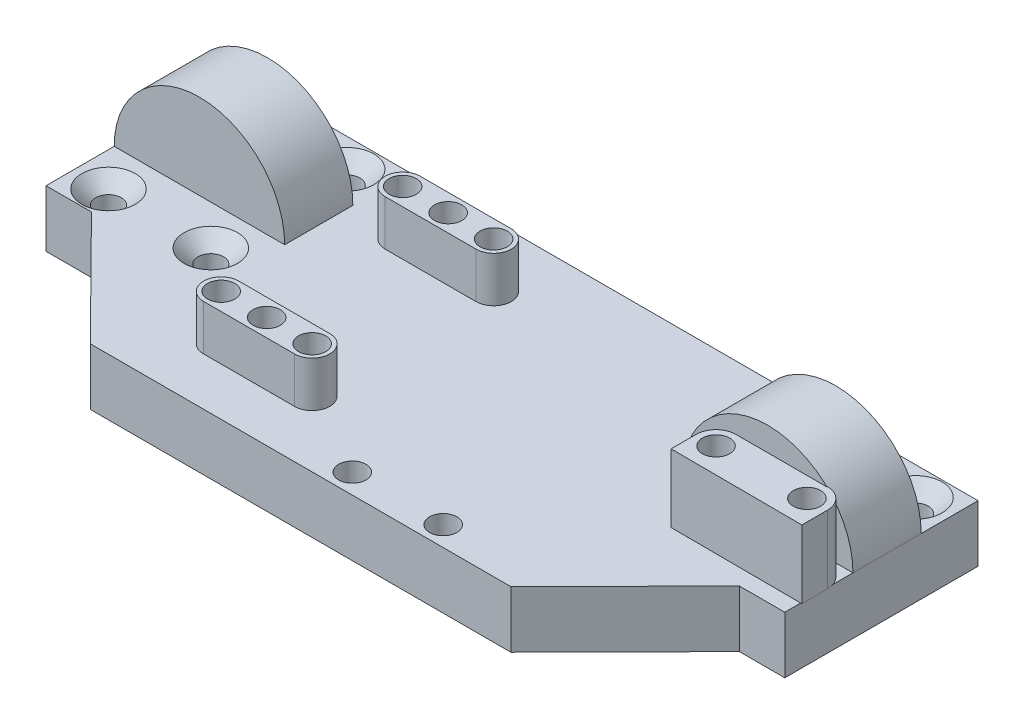
from build123d import *

# Parameters (mm, degrees)
BOSS_EXTRUDE1_DEPTH                             = 10
BOSS_EXTRUDE2_DEPTH                             = 10
SKETCH4_R                                       = 2.4
CUT_EXTRUDE1_DEPTH                              = 8
SKETCH5_R                                       = 2.4
BOSS_EXTRUDE3_DEPTH                             = 12
CSK_FOR_M4_FLAT_HEAD_MACHINE_SCREW1_D           = 4.5
CSK_FOR_M4_FLAT_HEAD_MACHINE_SCREW1_DEPTH       = 10
CSK_FOR_M4_FLAT_HEAD_MACHINE_SCREW1_CSINK_D     = 9.4
CSK_FOR_M4_FLAT_HEAD_MACHINE_SCREW1_CSINK_ANGLE = 90
SKETCH10_R                                      = 2.4
BOSS_EXTRUDE4_DEPTH                             = 8
SKETCH11_R                                      = 4
BOSS_EXTRUDE5_DEPTH                             = 12
SKETCH12_R                                      = 4
BOSS_EXTRUDE6_DEPTH                             = 4


with BuildPart() as part:
    # Sketch2 → Boss-Extrude1 (new body)
    with BuildSketch(Plane(origin=(0, 0, 0), x_dir=(1, 0, 0), z_dir=(0, 1, 0))):
        Polygon((-64.864315762, -10.473994627), (-34.864315762, -10.473994627), (35.135684238, -10.473994627), (65.135684238, -10.473994627), (65.135684238, 23.526005373), (35.135684238, 23.526005373), (-34.864315762, 23.526005373), (-64.864315762, 23.526005373), align=None)
    extrude(amount=BOSS_EXTRUDE1_DEPTH)

    # Sketch3 → Boss-Extrude2 (add)
    with BuildSketch(Plane.XZ):
        Polygon((-34.864315762, 10.473994627), (-17.766011303, 10.473994627), (-17.766011303, 10.772744439), (-17.766011303, 12.772744439), (-17.766011303, 30.672744439), (-36.864315762, 30.672744439), (-56.864315762, 10.473994627), align=None)
        Polygon((-17.766011303, 10.772744439), (-17.766011303, 10.473994627), (35.135684238, 10.473994627), (57.135684238, 10.473994627), (37.135684238, 30.672744439), (-17.766011303, 30.672744439), (-17.766011303, 12.772744439), align=None)
    extrude(amount=-BOSS_EXTRUDE2_DEPTH)

    # Sketch4 → Cut-Extrude1 (cut)
    with BuildSketch(Plane(origin=(0, 10, 0), x_dir=(1, 0, 0), z_dir=(0, 1, 0))):
        with Locations((5.733988697, -27.172744439)):
            Circle(SKETCH4_R)
        with Locations((21.733988697, -27.172744439)):
            Circle(SKETCH4_R)
    extrude(amount=-CUT_EXTRUDE1_DEPTH, mode=Mode.SUBTRACT)

    # Sketch5 → Boss-Extrude3 (add)
    with BuildSketch(Plane(origin=(0, 10, 0), x_dir=(1, 0, 0), z_dir=(0, 1, 0))):
        with BuildLine():
            Line((42.233988697, -7.572744439), (65.333988697, -7.672744439))
            Line((65.333988697, -7.672744439), (65.333988697, -3.172744439))
            ThreePointArc((65.333988697, -3.172744439), (64.279573109, -0.627160027), (61.733988697, 0.427255561))
            Line((61.733988697, 0.427255561), (61.733988697, 0.327255561))
            Line((61.733988697, 0.327255561), (45.733988697, 0.327255561))
            ThreePointArc((45.733988697, 0.327255561), (43.259114963, -0.697870705), (42.233988697, -3.172744439))
            Line((42.233988697, -3.172744439), (42.233988697, -7.572744439))
        make_face()
        with Locations((61.733988697, -3.172744439)):
            Circle(SKETCH5_R, mode=Mode.SUBTRACT)
        with Locations((45.733988697, -3.172744439)):
            Circle(SKETCH5_R, mode=Mode.SUBTRACT)
    extrude(amount=BOSS_EXTRUDE3_DEPTH)

    # CSK for M4 Flat Head Machine Screw1
    with Locations(Plane(origin=(0, 10, 0), x_dir=(1, 0, 0), z_dir=(0, 1, 0))):
        with Locations((-58.864315762, 18.526005373), (-40.864315762, 18.526005373), (-58.864315762, -5.473994627), (-40.864315762, -5.473994627), (41.135684238, 18.526005373), (59.135684238, 18.526005373)):
            CounterSinkHole(CSK_FOR_M4_FLAT_HEAD_MACHINE_SCREW1_D / 2, CSK_FOR_M4_FLAT_HEAD_MACHINE_SCREW1_CSINK_D / 2, depth=CSK_FOR_M4_FLAT_HEAD_MACHINE_SCREW1_DEPTH, counter_sink_angle=CSK_FOR_M4_FLAT_HEAD_MACHINE_SCREW1_CSINK_ANGLE)

    # Sketch10 → Boss-Extrude4 (add)
    with BuildSketch(Plane(origin=(0, 10, 0), x_dir=(1, 0, 0), z_dir=(0, 1, 0))):
        with BuildLine():
            Line((-25.366011303, -16.042744439), (-9.366011303, -16.042744439))
            ThreePointArc((-9.366011303, -16.042744439), (-6.266011303, -19.142744439), (-9.366011303, -22.242744439))
            Line((-9.366011303, -22.242744439), (-25.366011303, -22.242744439))
            ThreePointArc((-25.366011303, -22.242744439), (-28.466011303, -19.142744439), (-25.366011303, -16.042744439))
        make_face()
        with Locations((-25.366011303, -19.142744439)):
            Circle(SKETCH10_R, mode=Mode.SUBTRACT)
        with Locations((-17.366011303, -19.142744439)):
            Circle(SKETCH10_R, mode=Mode.SUBTRACT)
        with Locations((-9.366011303, -19.142744439)):
            Circle(SKETCH10_R, mode=Mode.SUBTRACT)
        with BuildLine():
            Line((-25.366011303, 9.697255561), (-9.366011303, 9.697255561))
            ThreePointArc((-9.366011303, 9.697255561), (-6.266011303, 12.797255561), (-9.366011303, 15.897255561))
            Line((-9.366011303, 15.897255561), (-25.366011303, 15.897255561))
            ThreePointArc((-25.366011303, 15.897255561), (-28.466011303, 12.797255561), (-25.366011303, 9.697255561))
        make_face()
        with Locations((-9.366011303, 12.797255561)):
            Circle(SKETCH10_R, mode=Mode.SUBTRACT)
        with Locations((-17.366011303, 12.797255561)):
            Circle(SKETCH10_R, mode=Mode.SUBTRACT)
        with Locations((-25.366011303, 12.797255561)):
            Circle(SKETCH10_R, mode=Mode.SUBTRACT)
    extrude(amount=BOSS_EXTRUDE4_DEPTH)

    # Sketch11 → Boss-Extrude5 (add)
    with BuildSketch(Plane(origin=(0, 0, -13.526005373), x_dir=(-1, 0, 0), z_dir=(0, 0, -1))):
        with BuildLine():
            Line((-65.135684238, 10), (-35.135684238, 10))
            ThreePointArc((-35.135684238, 10), (-50.135684238, 25), (-65.135684238, 10))
        make_face()
        with Locations((-50.135684238, 16.7)):
            Circle(SKETCH11_R, mode=Mode.SUBTRACT)
    boss_extrude5 = extrude(amount=-BOSS_EXTRUDE5_DEPTH)

    # Sketch12 → Boss-Extrude6 (add)
    with BuildSketch(Plane.XY.offset(-1.526005373)):
        with Locations((50.135684238, 16.7)):
            Circle(SKETCH12_R)
    boss_extrude6 = extrude(amount=-BOSS_EXTRUDE6_DEPTH)

    # Mirror1: Boss-Extrude5, Boss-Extrude6 across plane
    add(boss_extrude5.mirror(Plane(origin=(0.135684238, 0, 0), x_dir=(0, 0, 1), z_dir=(1, 0, 0))))
    add(boss_extrude6.mirror(Plane(origin=(0.135684238, 0, 0), x_dir=(0, 0, 1), z_dir=(1, 0, 0))))


solid = part.part
